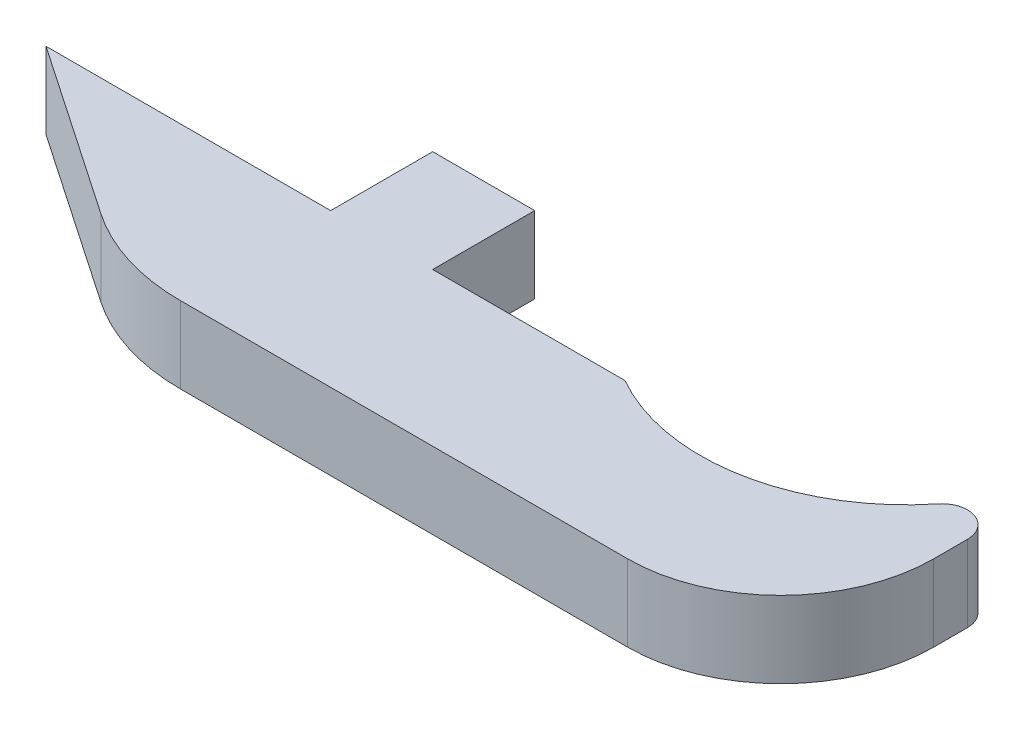
from build123d import *

# Parameters (mm, degrees)
BOSS_EXTRUDE1_DEPTH = 4.7625
FILLET1_R           = 9.525
FILLET2_R           = 1.5875
FILLET4_R           = 12.7
SKETCH2_W           = 6.35
SKETCH2_H           = 6.35
BOSS_EXTRUDE2_DEPTH = 4.7625


with BuildPart() as part:
    # Sketch1 → Boss-Extrude1 (new body)
    with BuildSketch(Plane(origin=(0, 0, 0), x_dir=(1, 0, 0), z_dir=(0, 1, 0))):
        with BuildLine():
            ThreePointArc((58.42, 11.1252), (52.020983, 0.025067), (39.208499, 0))
            Line((39.208499, 0), (3.175, 0))
            Line((3.175, 0), (17.145, -9.525))
            Line((17.145, -9.525), (58.42, -9.525))
            Line((58.42, -9.525), (58.42, 11.1252))
        make_face()
    extrude(amount=BOSS_EXTRUDE1_DEPTH)

    # Fillet1
    fillet1_edges = [part.edges().sort_by_distance(p)[0] for p in [
        (58.42, 2.38125, 9.525),
    ]]
    fillet(fillet1_edges, radius=FILLET1_R)

    # Fillet2
    fillet2_edges = [part.edges().sort_by_distance(p)[0] for p in [
        (58.42, 2.38125, -11.1252),
    ]]
    fillet(fillet2_edges, radius=FILLET2_R)

    # Fillet4
    fillet4_edges = [part.edges().sort_by_distance(p)[0] for p in [
        (17.145, 2.38125, 9.525),
    ]]
    fillet(fillet4_edges, radius=FILLET4_R)

    # Sketch2 → Boss-Extrude2 (add)
    with BuildSketch(Plane.XZ):
        with Locations((24.0645, -3.175)):
            Rectangle(SKETCH2_W, SKETCH2_H)
    extrude(amount=-BOSS_EXTRUDE2_DEPTH)


solid = part.part
